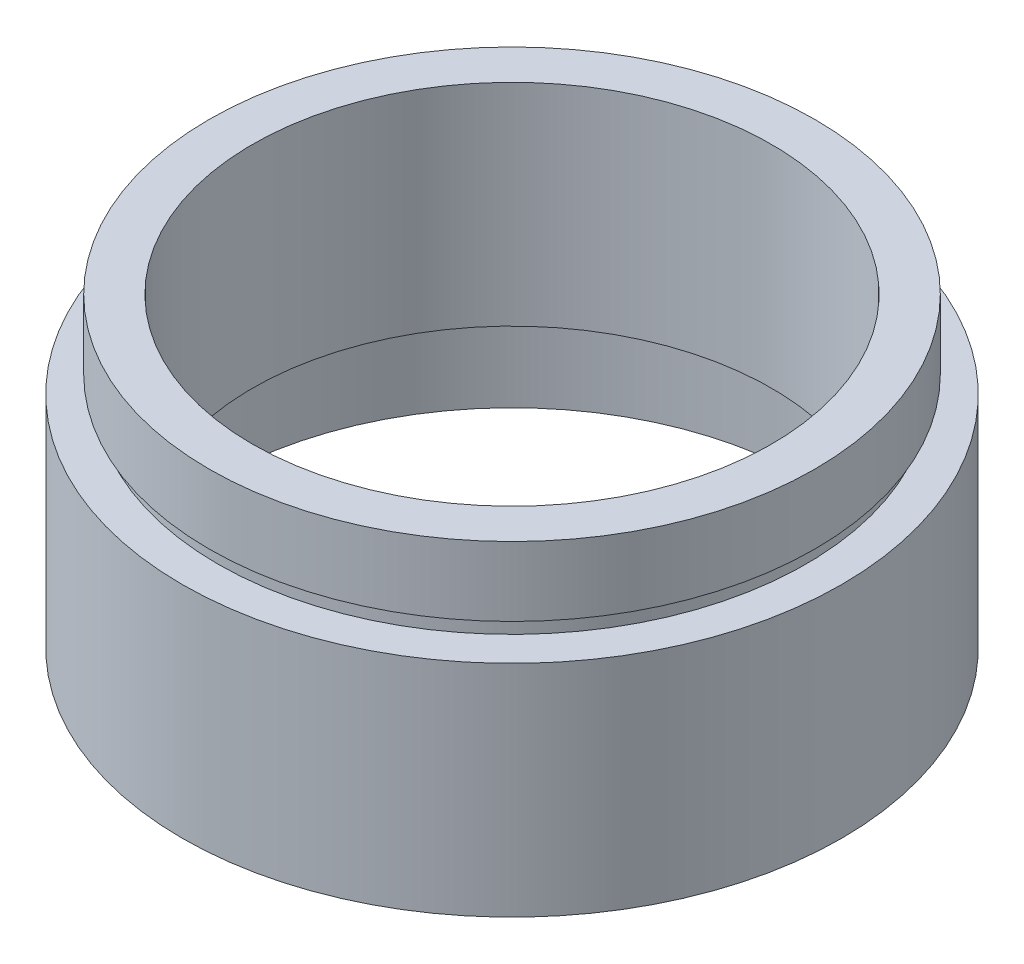
from build123d import *


with BuildPart() as part:
    # 草图1 → 旋转1 (revolve)
    with BuildSketch(Plane.XY, mode=Mode.PRIVATE) as revolve_1_sk:
        Polygon((19.05, 0), (19.05, 12.7), (17, 12.7), (17, 13.7), (17.5, 13.7), (17.5, 17.7), (15, 17.7), (15, 5.5), (17.6, 5.5), (17.6, 4.5), (17, 4.5), (17, 0), align=None)
    revolve(revolve_1_sk.sketch.rotate(Axis((0, 161.376166943, 0), (0, -1, 0)), 90), axis=Axis((0, 161.376166943, 0), (0, -1, 0)))  # turned: the seam where the file's is


solid = part.part
